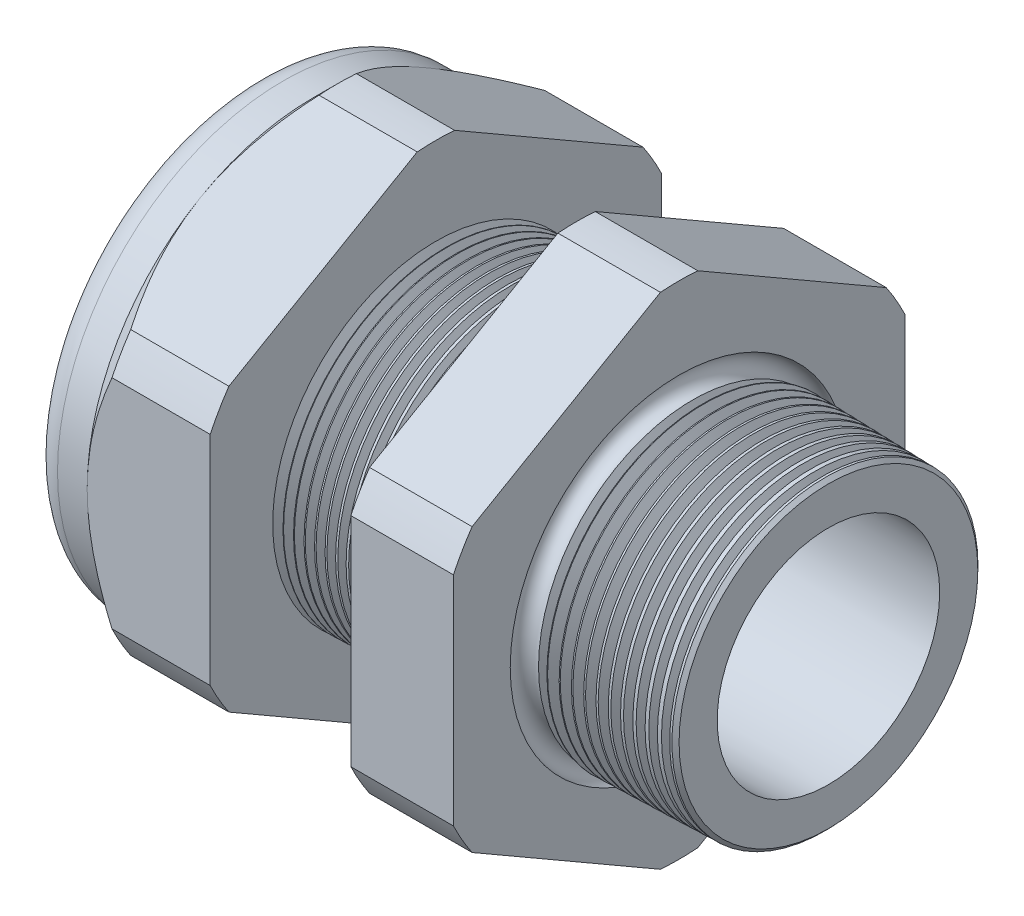
from build123d import *

# Parameters (mm, degrees)
SKETCH12_OUTSIDE_W = 88.514
SKETCH12_OUTSIDE_H = 88.514
CUT_EXTRUDE2_DEPTH = 38.71
FILLET4_R          = 2.032
SKETCH19_OUTSIDE_W = 55.962
SKETCH19_OUTSIDE_H = 59.594
SKETCH19_OUTSIDE_R = 16.51
CUT_EXTRUDE3_DEPTH = 3.99796
CUT_EXTRUDE3_DRAFT = -45
CHAMFER1_SIZE      = 0.260919487
CHAMFER1_SIZE2     = 0.254
SKETCH21_R         = 9.017
PLUG_DEPTH         = 8.89
SKETCH22_R         = 8.763
CUT_EXTRUDE4_DEPTH = 0.508
SKETCH27_R         = 2.54
PLUGHOLES_DEPTH    = 42.402
CIRPATTERN1_COUNT  = 3
LPATTERN1_COUNT    = 14
LPATTERN1_PITCH    = 0.762
LPATTERN2_COUNT    = 12
LPATTERN2_PITCH    = 0.889
SKETCH32_R         = 0.889


with BuildPart() as part:
    # Sketch10 → Revolve2 (revolve)
    with BuildSketch(Plane.XY, mode=Mode.PRIVATE) as revolve2_sk:
        Polygon((-38.862, 9.017), (-25.662, 9.017), (3.048, 8.138202192), (3.048, 11.186202192), (-7.874, 11.472204827), (-7.874, 33.02), (-15.374, 33.02), (-15.374, 11.668599239), (-25.662, 11.938), (-25.662, 33.02), (-34.662, 33.02), (-34.662, 16.51), (-38.862, 16.51), align=None)
    revolve(revolve2_sk.sketch.rotate(Axis((0, 0, 0), (-1, 0, 0)), 90), axis=Axis((0, 0, 0), (-1, 0, 0)))  # turned: the seam where the file's is

    # Sketch12 outside → Cut-Extrude2 (cut, through all)
    with BuildSketch(Plane.ZY.offset(34.662)):
        Rectangle(SKETCH12_OUTSIDE_W, SKETCH12_OUTSIDE_H)
        with BuildLine():
            Line((-1.366648898, 18.27507078), (-15.143351102, 10.321088053))
            ThreePointArc((-15.143351102, 10.321088053), (-15.870868152, 9.16305), (-16.51, 7.953982726))
            Line((-16.51, 7.953982726), (-16.51, -7.953982726))
            ThreePointArc((-16.51, -7.953982726), (-15.870868152, -9.16305), (-15.143351102, -10.321088053))
            Line((-15.143351102, -10.321088053), (-1.366648898, -18.27507078))
            ThreePointArc((-1.366648898, -18.27507078), (0, -18.3261), (1.366648898, -18.27507078))
            Line((1.366648898, -18.27507078), (15.143351102, -10.321088053))
            ThreePointArc((15.143351102, -10.321088053), (15.870868152, -9.16305), (16.51, -7.953982726))
            Line((16.51, -7.953982726), (16.51, 7.953982726))
            ThreePointArc((16.51, 7.953982726), (15.870868152, 9.16305), (15.143351102, 10.321088053))
            Line((15.143351102, 10.321088053), (1.366648898, 18.27507078))
            ThreePointArc((1.366648898, 18.27507078), (0, 18.3261), (-1.366648898, 18.27507078))
        make_face(mode=Mode.SUBTRACT)
    extrude(amount=-CUT_EXTRUDE2_DEPTH, mode=Mode.SUBTRACT)

    # Fillet4
    fillet4_edges = [part.edges().sort_by_distance(p)[0] for p in [
        (-38.862, 0, 16.51),
    ]]
    fillet(fillet4_edges, radius=FILLET4_R)


with BuildPart() as cut_extrude3_tool:
    # Sketch19 outside → Cut-Extrude3 (with draft: the straight prism first)
    with BuildSketch(Plane.ZY.offset(34.662)):
        Rectangle(SKETCH19_OUTSIDE_W, SKETCH19_OUTSIDE_H)
        Circle(SKETCH19_OUTSIDE_R, mode=Mode.SUBTRACT)
    extrude(amount=-CUT_EXTRUDE3_DEPTH)
    # Cut-Extrude3: the draft: its side faces are tilted about the plane it starts from
    cut_extrude3_sides = [cut_extrude3_tool.faces().sort_by_distance(p)[0] for p in [
        (-32.66302, -29.797, 0),
        (-32.66302, 0, 27.981),
        (-32.66302, 29.797, 0),
        (-32.66302, 0, -27.981),
        (-32.66302, 0, -16.51),
    ]]
    draft(cut_extrude3_sides, Plane.ZY.offset(34.662), CUT_EXTRUDE3_DRAFT)


with BuildPart() as part_1:
    add(part.part)

    # Cut-Extrude3: cut by cut_extrude3_tool
    add(cut_extrude3_tool.part, mode=Mode.SUBTRACT)

    # Chamfer1
    chamfer1_edges = [part_1.edges().sort_by_distance(p)[0] for p in [
        (3.048, 0, 11.186202192),
    ]]
    chamfer1_side = [part_1.faces().sort_by_distance(p)[0] for p in [
        (3.048, 0, 8.454595769),
    ]]
    chamfer(chamfer1_edges, length=CHAMFER1_SIZE, length2=CHAMFER1_SIZE2, reference=chamfer1_side[0])

    # Sketch29 → Cut-Revolve1 (revolve, cut)
    with BuildSketch(Plane.XY, mode=Mode.PRIVATE) as cut_revolve1_sk:
        Polygon((-25.662, 11.938), (-24.929016419, 11.918806149), (-25.312130572, 11.293620673), align=None)
    cut_revolve1 = revolve(cut_revolve1_sk.sketch.rotate(Axis((0, 0, 0), (-1, 0, 0)), 90), axis=Axis((0, 0, 0), (-1, 0, 0)), mode=Mode.SUBTRACT)  # turned: the seam where the file's is

    # LPattern1: Cut-Revolve1 ×14
    with Locations(*[(i * LPATTERN1_PITCH, 0, 0) for i in range(1, LPATTERN1_COUNT)]):
        add(cut_revolve1, mode=Mode.SUBTRACT)

    # Sketch30 → Cut-Revolve2 (revolve, cut)
    with BuildSketch(Plane.XY, mode=Mode.PRIVATE) as cut_revolve2_sk:
        Polygon((-7.874, 11.472204827), (-6.994419703, 11.449172206), (-7.454156686, 10.698949635), align=None)
    cut_revolve2 = revolve(cut_revolve2_sk.sketch.rotate(Axis((0, 0, 0), (-1, 0, 0)), 270), axis=Axis((0, 0, 0), (-1, 0, 0)), mode=Mode.SUBTRACT)  # turned: the seam where the file's is

    # LPattern2: Cut-Revolve2 ×12
    with Locations(*[(i * LPATTERN2_PITCH, 0, 0) for i in range(1, LPATTERN2_COUNT)]):
        add(cut_revolve2, mode=Mode.SUBTRACT)

    # Sketch32 → Cut-Revolve3 (revolve, cut)
    with BuildSketch(Plane.XY, mode=Mode.PRIVATE) as cut_revolve3_sk:
        with Locations((-7.747, 11.472204827)):
            Circle(SKETCH32_R)
    revolve(cut_revolve3_sk.sketch.rotate(Axis((0, 0, 0), (-1, 0, 0)), 270), axis=Axis((0, 0, 0), (-1, 0, 0)), mode=Mode.SUBTRACT)  # turned: the seam where the file's is


with BuildPart() as body_2:
    # Sketch21 → plug (new body)
    with BuildSketch(Plane.ZY.offset(38.862)):
        Circle(SKETCH21_R)
    extrude(amount=-PLUG_DEPTH)

    # Sketch22 → Cut-Extrude4 (cut)
    with BuildSketch(Plane.ZY.offset(38.862)):
        Circle(SKETCH22_R)
    extrude(amount=-CUT_EXTRUDE4_DEPTH, mode=Mode.SUBTRACT)

    # Sketch27 → plugholes (cut, through all)
    with BuildSketch(Plane.ZY.offset(38.354)):
        with Locations((-6.21284, 0)):
            Circle(SKETCH27_R)
    plugholes = extrude(amount=-PLUGHOLES_DEPTH, mode=Mode.SUBTRACT)

    # CirPattern1: plugholes ×3 about axis
    cirpattern1_axis = Axis((0, 0, 0), (1, 0, 0))
    for i in range(1, CIRPATTERN1_COUNT):
        add(plugholes.rotate(cirpattern1_axis, i * 360 / CIRPATTERN1_COUNT), mode=Mode.SUBTRACT)


solid = Compound([part_1.part, body_2.part])
